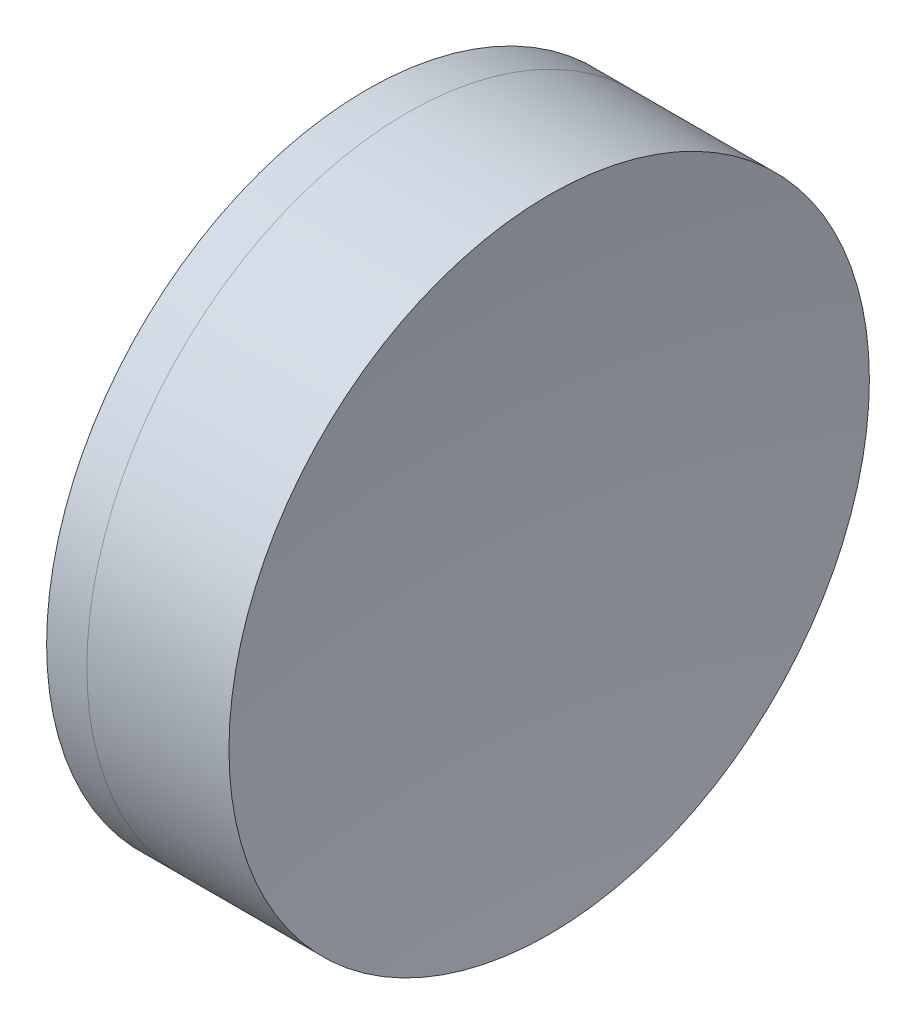
from build123d import *


with BuildPart() as part:
    # 草图1 one side → 旋转1 (revolve)
    with BuildSketch(Plane(origin=(0, 0, 0), x_dir=(1, 0, 0), z_dir=(0, 1, 0)), mode=Mode.PRIVATE) as revolve_1_sk:
        with BuildLine():
            ThreePointArc((96.590654899, 15), (93.521084336, 7.777457099), (92.472966749, 0))
            Line((92.472966749, 0), (101.972966749, 0))
            ThreePointArc((101.972966749, 0), (101.086883108, 7.701236802), (98.47493972, 15))
            Line((98.47493972, 15), (96.590654899, 15))
        make_face()
    revolve(revolve_1_sk.sketch.rotate(Axis((-0.816062176, 0, 0), (1, 0, 0)), 180), axis=Axis((-0.816062176, 0, 0), (1, 0, 0)))  # turned: the seam where the file's is


with BuildPart() as body_2:
    # 草图2 one side → 旋转2 (revolve)
    with BuildSketch(Plane(origin=(0, 0, 0), x_dir=(1, 0, 0), z_dir=(0, 1, 0)), mode=Mode.PRIVATE) as revolve_2_sk:
        with BuildLine():
            Line((105.131077786, 15), (98.47493972, 15))
            ThreePointArc((98.47493972, 15), (101.086883108, 7.701236802), (101.972966749, 0))
            Line((101.972966749, 0), (103.972966749, 0))
            ThreePointArc((103.972966749, 0), (104.262924694, 7.522320473), (105.131077786, 15))
        make_face()
    revolve(revolve_2_sk.sketch.rotate(Axis((-0.551919993, 0, 0), (1, 0, 0)), 180), axis=Axis((-0.551919993, 0, 0), (1, 0, 0)))  # turned: the seam where the file's is


solid = Compound([part.part, body_2.part])
